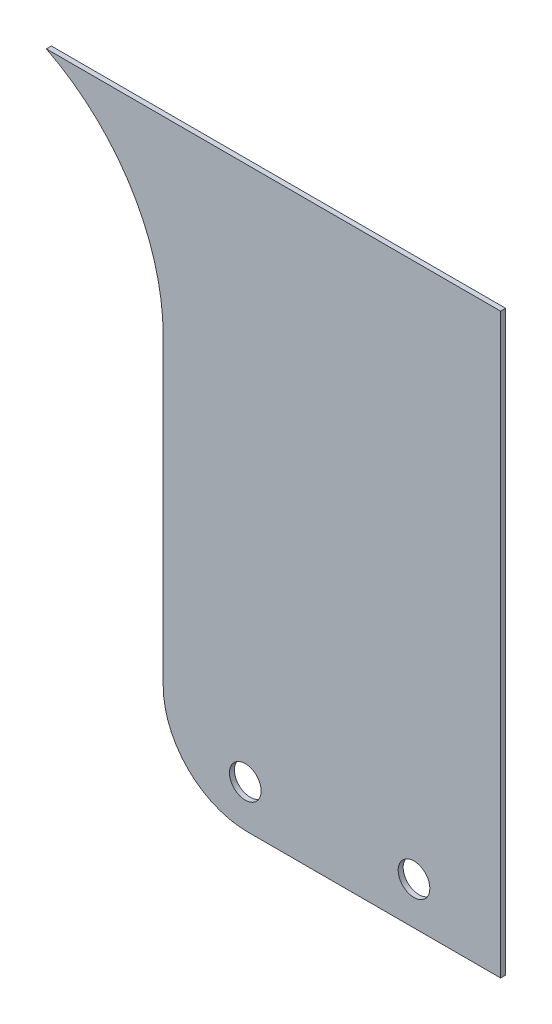
from build123d import *

# Parameters (mm, degrees)
SKETCH1_R      = 4.7625
EXTRUDE1_DEPTH = 1.5


with BuildPart() as part:
    # Sketch1 → Extrude1 (new body)
    with BuildSketch(Plane.XY.offset(165.1)):
        with BuildLine():
            Line((-418.175, 962.43), (-554.955743448, 962.43))
            ThreePointArc((-554.955743448, 962.43), (-529.269854117, 938.688748088), (-519.775, 905.024825288))
            Line((-519.775, 905.024825288), (-519.775, 813.93))
            ThreePointArc((-519.775, 813.93), (-512.335512242, 795.969487758), (-494.375, 788.53))
            Line((-494.375, 788.53), (-418.175, 788.53))
            Line((-418.175, 788.53), (-418.175, 962.43))
        make_face()
        with Locations((-444.2625, 801.23)):
            Circle(SKETCH1_R, mode=Mode.SUBTRACT)
        with Locations((-495.0625, 801.23)):
            Circle(SKETCH1_R, mode=Mode.SUBTRACT)
    extrude(amount=EXTRUDE1_DEPTH)


solid = part.part
